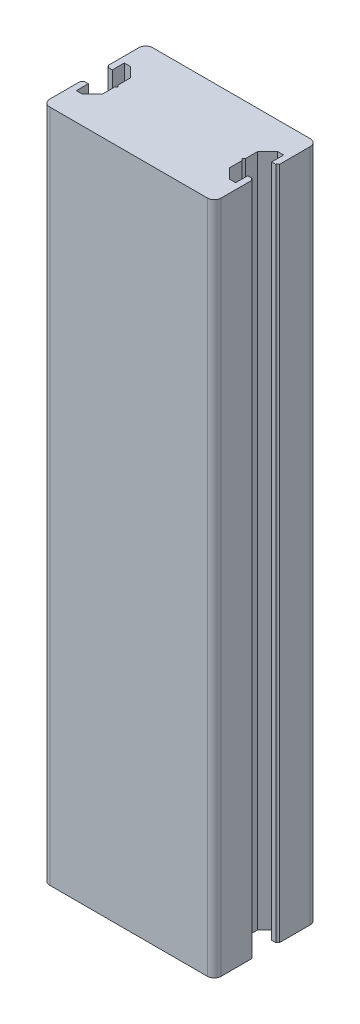
from build123d import *

# Parameters (mm, degrees)
BOSS_EXTRUDE1_DEPTH = 295
FILLET1_R           = 3
SKETCH2_R           = 1.5
CUT_EXTRUDE1_DEPTH  = 10


with BuildPart() as part:
    # Sketch1 → Boss-Extrude1 (new body)
    with BuildSketch(Plane(origin=(0, 0, 0), x_dir=(1, 0, 0), z_dir=(0, 1, 0))):
        with BuildLine():
            Line((2.625, 17.250000178), (0.75, 17.250000178))
            ThreePointArc((0.75, 17.250000178), (0.530330086, 16.719670092), (0, 16.500000178))
            Line((0, 16.500000178), (0, 0))
            Line((0, 0), (75, 0))
            Line((75, 0), (75, 16.500000178))
            ThreePointArc((75, 16.500000178), (74.469669914, 16.719670092), (74.25, 17.250000178))
            Line((74.25, 17.250000178), (72.375, 17.250000178))
            Line((72.375, 17.250000178), (72.375, 12.000000178))
            Line((72.375, 12.000000178), (69.75, 12.000000178))
            Line((69.75, 12.000000178), (65.375, 16.375))
            Line((65.375, 16.375), (65.375, 21.75))
            Line((65.375, 21.75), (64.625, 22.5))
            Line((64.625, 22.5), (65.375, 23.25))
            Line((65.375, 23.25), (65.375, 28.625))
            Line((65.375, 28.625), (69.75, 33.000000178))
            Line((69.75, 33.000000178), (72.375, 33.000000178))
            Line((72.375, 33.000000178), (72.375, 27.750000178))
            Line((72.375, 27.750000178), (74.25, 27.750000178))
            ThreePointArc((74.25, 27.750000178), (74.469669914, 28.280330264), (75, 28.500000178))
            Line((75, 28.500000178), (75, 45))
            Line((75, 45), (0, 45))
            Line((0, 45), (0, 28.500000178))
            ThreePointArc((0, 28.500000178), (0.530330086, 28.280330264), (0.75, 27.750000178))
            Line((0.75, 27.750000178), (2.625, 27.750000178))
            Line((2.625, 27.750000178), (2.625, 33.000000178))
            Line((2.625, 33.000000178), (5.25, 33.000000178))
            Line((5.25, 33.000000178), (9.625, 28.625))
            Line((9.625, 28.625), (9.625, 23.25))
            Line((9.625, 23.25), (10.375, 22.5))
            Line((10.375, 22.5), (9.625, 21.75))
            Line((9.625, 21.75), (9.625, 16.375))
            Line((9.625, 16.375), (5.25, 12.000000178))
            Line((5.25, 12.000000178), (2.625, 12.000000178))
            Line((2.625, 12.000000178), (2.625, 17.250000178))
        make_face()
    extrude(amount=BOSS_EXTRUDE1_DEPTH)

    # Fillet1
    fillet1_edges = [part.edges().sort_by_distance(p)[0] for p in [
        (0, 147.5, 0),
        (0, 147.5, -45),
        (75, 147.5, -45),
        (75, 147.5, 0),
    ]]
    fillet(fillet1_edges, radius=FILLET1_R)

    # Sketch2 → Cut-Extrude1 (cut)
    with BuildSketch(Plane(origin=(0, 0, -45), x_dir=(-1, 0, 0), z_dir=(0, 0, -1))):
        with Locations((-6.5, 287)):
            Circle(SKETCH2_R)
        with Locations((-6.5, 247)):
            Circle(SKETCH2_R)
        with Locations((-6.5, 48)):
            Circle(SKETCH2_R)
        with Locations((-6.5, 8)):
            Circle(SKETCH2_R)
        with Locations((-68.5, 8)):
            Circle(SKETCH2_R)
        with Locations((-68.5, 48)):
            Circle(SKETCH2_R)
        with Locations((-68.5, 287)):
            Circle(SKETCH2_R)
        with Locations((-68.5, 247)):
            Circle(SKETCH2_R)
    extrude(amount=-CUT_EXTRUDE1_DEPTH, mode=Mode.SUBTRACT)


solid = part.part
